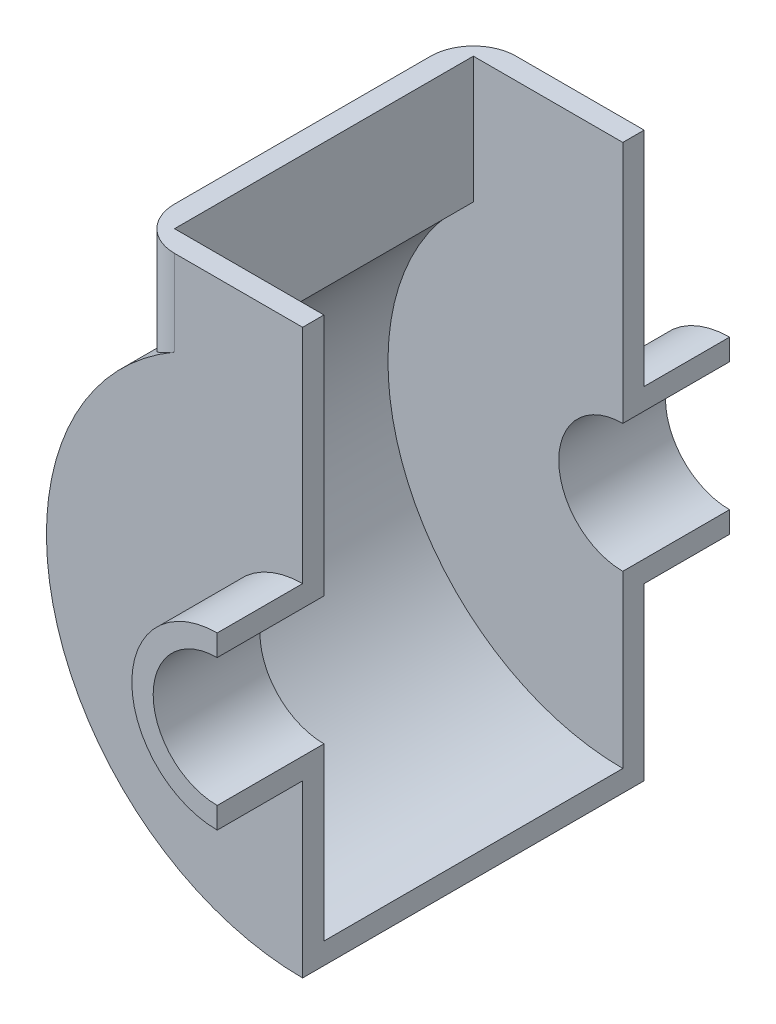
from build123d import *

# Parameters (mm, degrees)
DODANIE_WYCI_GNI_CIE1_DEPTH       = 25
DODANIE_WYCI_GNI_CIE2_DEPTH       = 5
WYCI_GNI_CIE_CIENKA_START         = -70
WYCI_GNI_CIE_CIENKA_CIANKA1_DEPTH = 70
ZAOKR_GLENIE1_R                   = 10


with BuildPart() as part:
    # Szkic1 → Dodanie-wyciągnięcie1 (new body)
    with BuildSketch(Plane.XY):
        with BuildLine():
            Line((0, 20), (0, 15))
            ThreePointArc((0, 15), (-15, 0), (0, -15))
            Line((0, -15), (0, -20))
            ThreePointArc((0, -20), (-20, 0), (0, 20))
        make_face()
    extrude(amount=DODANIE_WYCI_GNI_CIE1_DEPTH)

    # Szkic2 → Dodanie-wyciągnięcie2 (add)
    with BuildSketch(Plane.XY):
        with BuildLine():
            Line((0, 20), (0, 72))
            Line((0, 72), (-40, 72))
            Line((-40, 72), (-40, 44.72135955))
            ThreePointArc((-40, 44.72135955), (-56.050341538, -21.409325386), (0, -60))
            Line((0, -60), (0, -20))
            ThreePointArc((0, -20), (-20, 0), (0, 20))
        make_face()
    extrude(amount=DODANIE_WYCI_GNI_CIE2_DEPTH)


with BuildPart() as body_2:
    # Lustro1: mirrored copy
    add(part.part.mirror(Plane.XY.offset(-35)))


with BuildPart() as part_1:
    add(part.part)

    add(body_2.part)  # Wyciągnięcie-cienka ścianka1 merges body 2
    # Szkic3 → Wyciągnięcie-cienka ścianka1 (add)
    with BuildSketch(Plane.XY.offset(WYCI_GNI_CIE_CIENKA_START)):
        with BuildLine():
            Line((-40, 72), (-40, 44.72135955))
            ThreePointArc((-40, 44.72135955), (-56.050341538, -21.409325386), (0, -60))
            Line((0, -60), (0, -55))
            ThreePointArc((0, -55), (-51.76124215, -18.594994247), (-35, 42.426406871))
            Line((-35, 42.426406871), (-35, 72))
            Line((-35, 72), (-40, 72))
        make_face()
    extrude(amount=WYCI_GNI_CIE_CIENKA_CIANKA1_DEPTH)

    # Zaokrąglenie1
    zaokr_glenie1_edges = [part_1.edges().sort_by_distance(p)[0] for p in [
        (-40, 58.360679775, 5),
        (-40, 58.360679775, -75),
    ]]
    fillet(zaokr_glenie1_edges, radius=ZAOKR_GLENIE1_R)


solid = part_1.part
